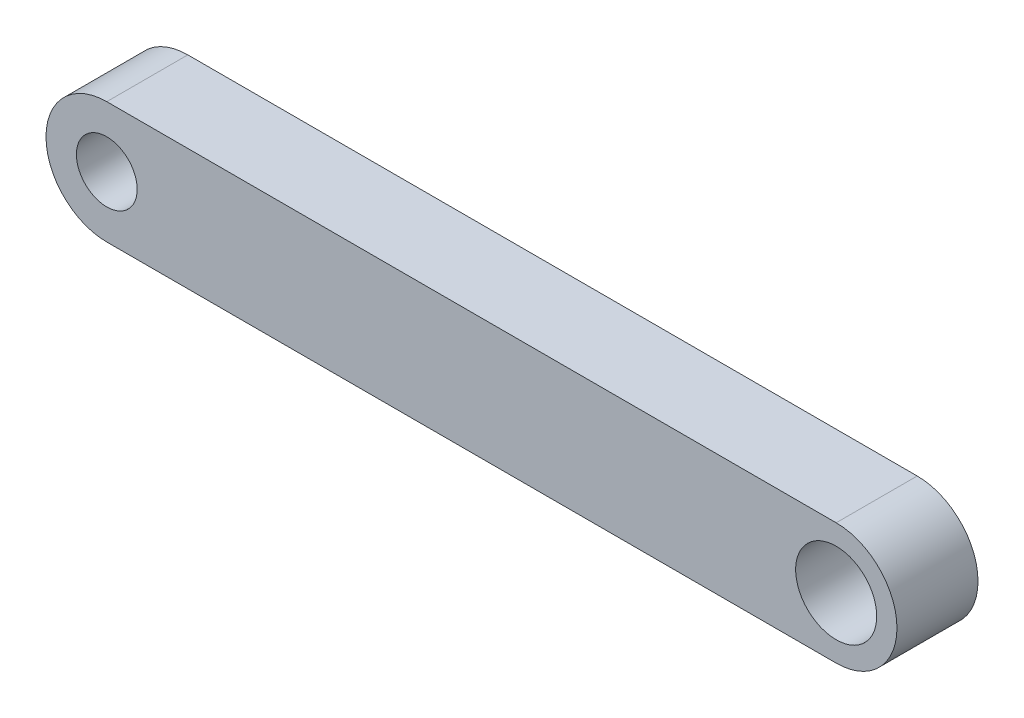
from build123d import *

# Parameters (mm, degrees)
SKETCH2_R           = 2
SKETCH2_R_2         = 1.5
BOSS_EXTRUDE1_DEPTH = 4


with BuildPart() as part:
    # Sketch2 → Boss-Extrude1 (new body)
    with BuildSketch(Plane.XY):
        with BuildLine():
            Line((0, 3), (-36, 3))
            ThreePointArc((-36, 3), (-39, 0), (-36, -3))
            Line((-36, -3), (0, -3))
            ThreePointArc((0, -3), (3, 0), (0, 3))
        make_face()
        Circle(SKETCH2_R, mode=Mode.SUBTRACT)
        with Locations((-36, 0)):
            Circle(SKETCH2_R_2, mode=Mode.SUBTRACT)
    extrude(amount=BOSS_EXTRUDE1_DEPTH)


solid = part.part
